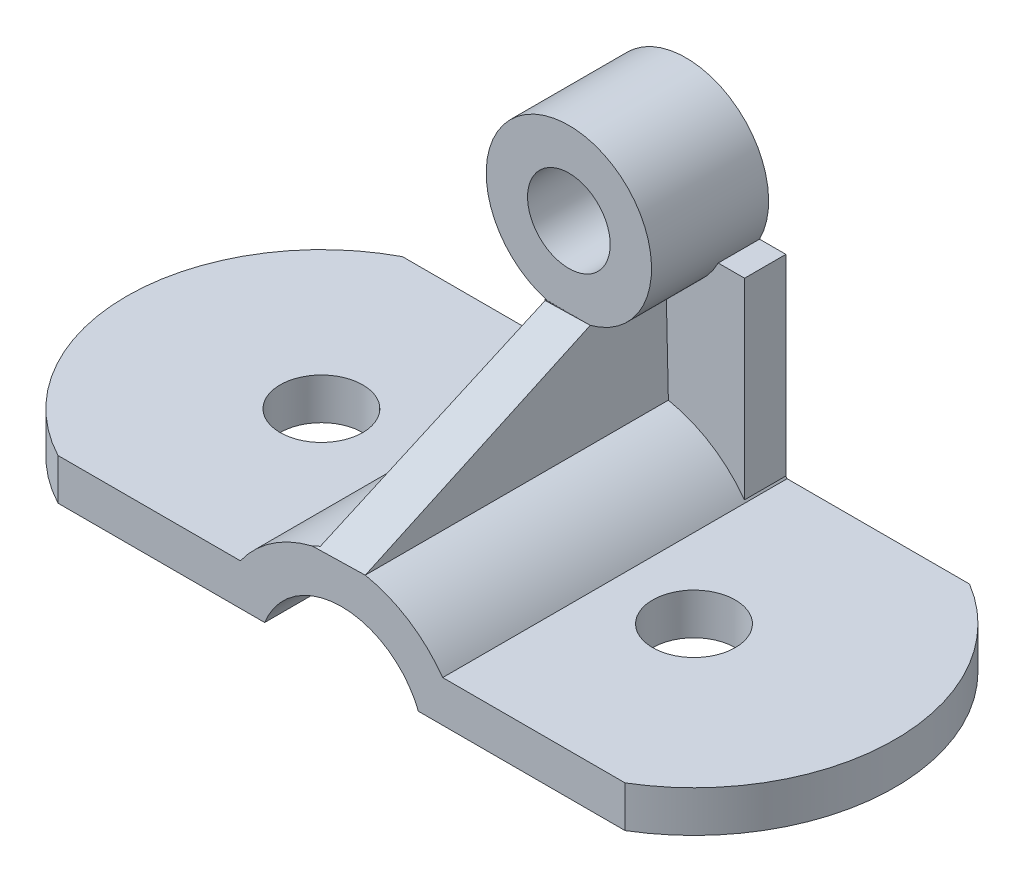
from build123d import *

# Parameters (mm, degrees)
BOSS_EXTRUDE2_DEPTH  = 100
SKETCH2_R            = 12
CUT_EXTRUDE2_DEPTH   = 100
BOSS_EXTRUDE3_DEPTH  = 12
SKETCH4_R            = 24
SKETCH4_R_2          = 12
BOSS_EXTRUDE4_DEPTH  = 34
SKETCH9_W            = 12
SKETCH9_H            = 56.23521347
BOSS_EXTRUDE14_DEPTH = 53
BOSS_EXTRUDE15_DEPTH = 100
CUT_EXTRUDE5_DEPTH   = 100
SKETCH18_W           = 10.631018499
SKETCH18_H           = 16.963963476
CUT_EXTRUDE6_DEPTH   = 2


with BuildPart() as part:
    # Sketch1 → Boss-Extrude2 (new body)
    with BuildSketch(Plane.XY):
        with BuildLine():
            Line((0, 0), (-60, 0))
            Line((-60, 0), (-60, 12))
            Line((-60, 12), (-7.046781234, 12))
            ThreePointArc((-7.046781234, 12), (22.318707009, 27.175300716), (51.684195251, 12))
            Line((51.684195251, 12), (104.637414017, 12))
            Line((104.637414017, 12), (104.637414017, 0))
            Line((104.637414017, 0), (44.637414017, 0))
            ThreePointArc((44.637414017, 0), (22.318707009, 15.175300716), (0, 0))
        make_face()
    extrude(amount=BOSS_EXTRUDE2_DEPTH)

    # Sketch2 → Cut-Extrude2 (cut)
    with BuildSketch(Plane(origin=(0, 0, 0), x_dir=(1, 0, 0), z_dir=(0, 1, 0))):
        with Locations((-33.523390617, -50)):
            Circle(SKETCH2_R)
        with Locations((74.637414017, -50)):
            Circle(SKETCH2_R)
    extrude(amount=CUT_EXTRUDE2_DEPTH, mode=Mode.SUBTRACT)

    # Sketch3 → Boss-Extrude3 (add)
    with BuildSketch(Plane(origin=(0, 0, 0), x_dir=(1, 0, 0), z_dir=(0, 1, 0))):
        with BuildLine():
            Line((-60, 0), (-60, -100))
            ThreePointArc((-60, -100), (-90.100867093, -50), (-60, 0))
        make_face()
        with BuildLine():
            Line((104.637414017, 0), (104.637414017, -100))
            ThreePointArc((104.637414017, -100), (132.946932966, -50), (104.637414017, 0))
        make_face()
    extrude(amount=BOSS_EXTRUDE3_DEPTH)



with BuildPart() as body_2:
    # Sketch4 → Boss-Extrude4 (new body)
    with BuildSketch(Plane.XY):
        with Locations((22.318707009, 79.175300716)):
            Circle(SKETCH4_R)
        with Locations((22.318707009, 79.175300716)):
            Circle(SKETCH4_R_2, mode=Mode.SUBTRACT)
    extrude(amount=BOSS_EXTRUDE4_DEPTH)


with BuildPart() as part_1:
    add(part.part)

    add(body_2.part)  # Boss-Extrude14 merges body 2
    # Sketch9 → Boss-Extrude14 (add)
    with BuildSketch(Plane.ZY.offset(1.681292991)):
        with Locations((6, 40.117606735)):
            Rectangle(SKETCH9_W, SKETCH9_H)
    extrude(amount=-BOSS_EXTRUDE14_DEPTH)

    # Sketch15 → Boss-Extrude15 (add)
    with BuildSketch(Plane.XY):
        Polygon((15.430799057, 55.991491628), (15.430799057, 26.510222876), (29.20661496, 26.510222876), (28.524429867, 55.991491628), align=None)
    extrude(amount=BOSS_EXTRUDE15_DEPTH)

    # Sketch16 → Cut-Extrude5 (cut)
    with BuildSketch(Plane(origin=(29.804092856, 0.689655118, 0), x_dir=(0, 0, -1), z_dir=(0.999732387, 0.023133419, 0))):
        Polygon((-34, 55.316639981), (-100, 25.827479536), (-100, 55.316639981), (-101.715628872, 69.701769469), (-35.158701994, 67.524066269), align=None)
    extrude(amount=-CUT_EXTRUDE5_DEPTH, mode=Mode.SUBTRACT)

    # Sketch18 → Cut-Extrude6 (cut)
    with BuildSketch(Plane(origin=(0, 68.23521347, 0), x_dir=(1, 0, 0), z_dir=(0, 1, 0))):
        with Locations((22.703243631, -8.481981738)):
            Rectangle(SKETCH18_W, SKETCH18_H)
    extrude(amount=-CUT_EXTRUDE6_DEPTH, mode=Mode.SUBTRACT)


solid = part_1.part
